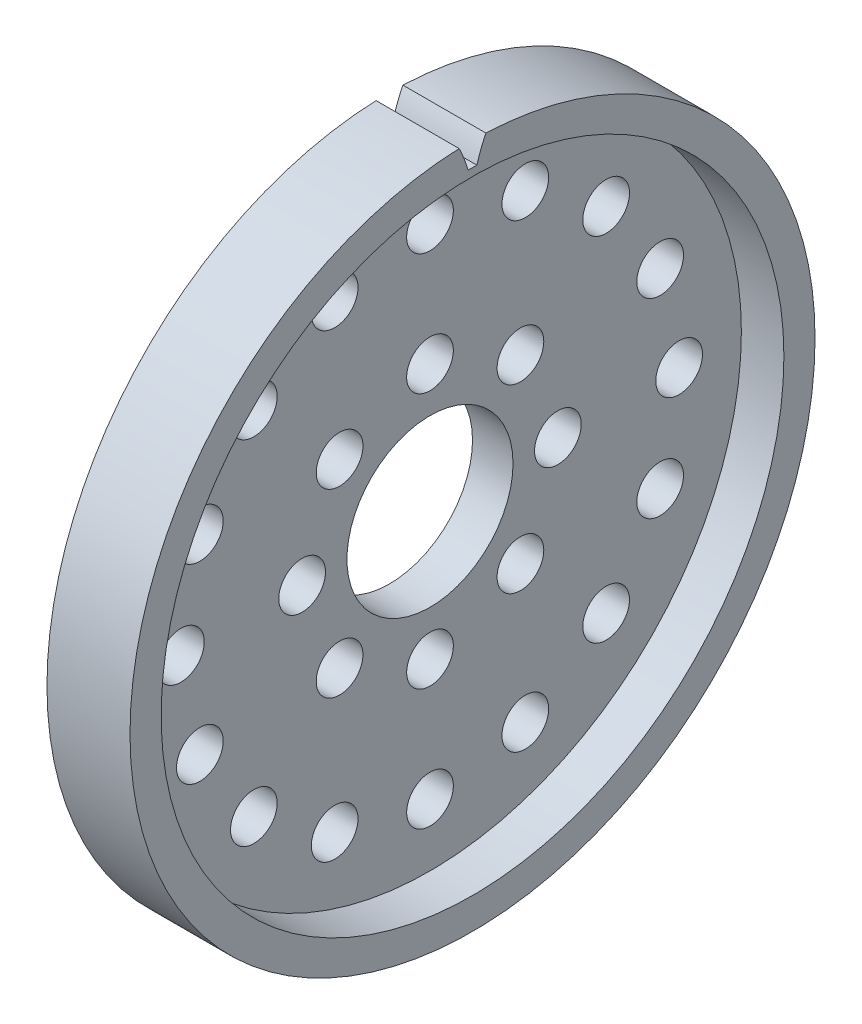
from build123d import *

# Parameters (mm, degrees)
BASPROSKE_W                         = 6.35
BASPROSKE_H                         = 26.19375
TOOTHCUT_DEPTH                      = 7.35
BORSKE_R                            = 6.35
BORE_DEPTH                          = 50.8000508
SKETCH1_R                           = 23.8125
CUT_EXTRUDE1_DEPTH                  = 3.2512
F_9_64_0_14063_DIAMETER_HOLE1_D     = 3.572002
F_9_64_0_14063_DIAMETER_HOLE1_DEPTH = 9.525
F_9_64_0_14063_DIAMETER_HOLE1_TIP   = 1.073137666


with BuildPart() as part:
    # BasProSke → Base-Revolve (revolve)
    with BuildSketch(Plane(origin=(0, 0, 0), x_dir=(1, 0, 0), z_dir=(0, 1, 0))):
        with Locations((3.175, 13.096875)):
            Rectangle(BASPROSKE_W, BASPROSKE_H)
    revolve(axis=Axis((-10, 0, 0), (1, 0, 0)))

    # TooCutSke → ToothCut (cut, through all)
    with BuildSketch(Plane(origin=(0, 0, 0), x_dir=(0, 0, -1), z_dir=(1, 0, 0))):
        with BuildLine():
            ThreePointArc((0.33374141, 24.394417139), (0, 24.3967), (-0.33374141, 24.394417139))
            ThreePointArc((-0.33374141, 24.394417139), (-0.642437388, 25.31332079), (-1.03730144, 26.19862272))
            ThreePointArc((-1.03730144, 26.19862272), (0, 26.21915), (1.03730144, 26.19862272))
            ThreePointArc((1.03730144, 26.19862272), (0.642437388, 25.31332079), (0.33374141, 24.394417139))
        make_face()
    extrude(amount=TOOTHCUT_DEPTH, mode=Mode.SUBTRACT)

    # BorSke → Bore (cut, symmetric)
    with BuildSketch(Plane(origin=(0, 0, 0), x_dir=(0, 0, -1), z_dir=(1, 0, 0))):
        Circle(BORSKE_R)
    extrude(amount=BORE_DEPTH, both=True, mode=Mode.SUBTRACT)

    # Sketch1 → Cut-Extrude1 (cut)
    with BuildSketch(Plane(origin=(6.35, 0, 0), x_dir=(0, 0, -1), z_dir=(1, 0, 0))):
        Circle(SKETCH1_R)
    extrude(amount=-CUT_EXTRUDE1_DEPTH, mode=Mode.SUBTRACT)

    # 9/64 (0.14063) Diameter Hole1
    with Locations(Plane(origin=(3.0988, 0, 0), x_dir=(0, 0, -1), z_dir=(1, 0, 0))):
        with Locations((0, 9.779), (0, 19.05), (7.290119387, 17.599905094), (13.470384182, 13.470384182), (17.599905094, 7.290119387), (19.05, 0), (17.599905094, -7.290119387), (13.470384182, -13.470384182), (7.290119387, -17.599905094), (0, -19.05), (-7.290119387, -17.599905094), (-13.470384182, -13.470384182), (-17.599905094, -7.290119387), (-19.05, 0), (-17.599905094, 7.290119387), (-13.470384182, 13.470384182), (-7.290119387, 17.599905094), (6.914797213, 6.914797213), (9.779, 0), (6.914797213, -6.914797213), (0, -9.779), (-6.914797213, -6.914797213), (-9.779, 0), (-6.914797213, 6.914797213)):
            Hole(F_9_64_0_14063_DIAMETER_HOLE1_D / 2, depth=F_9_64_0_14063_DIAMETER_HOLE1_DEPTH)
            with Locations((0, 0, -(F_9_64_0_14063_DIAMETER_HOLE1_DEPTH + F_9_64_0_14063_DIAMETER_HOLE1_TIP / 2))):  # 118° drill point
                Cone(0, F_9_64_0_14063_DIAMETER_HOLE1_D / 2, F_9_64_0_14063_DIAMETER_HOLE1_TIP, mode=Mode.SUBTRACT)


solid = part.part
